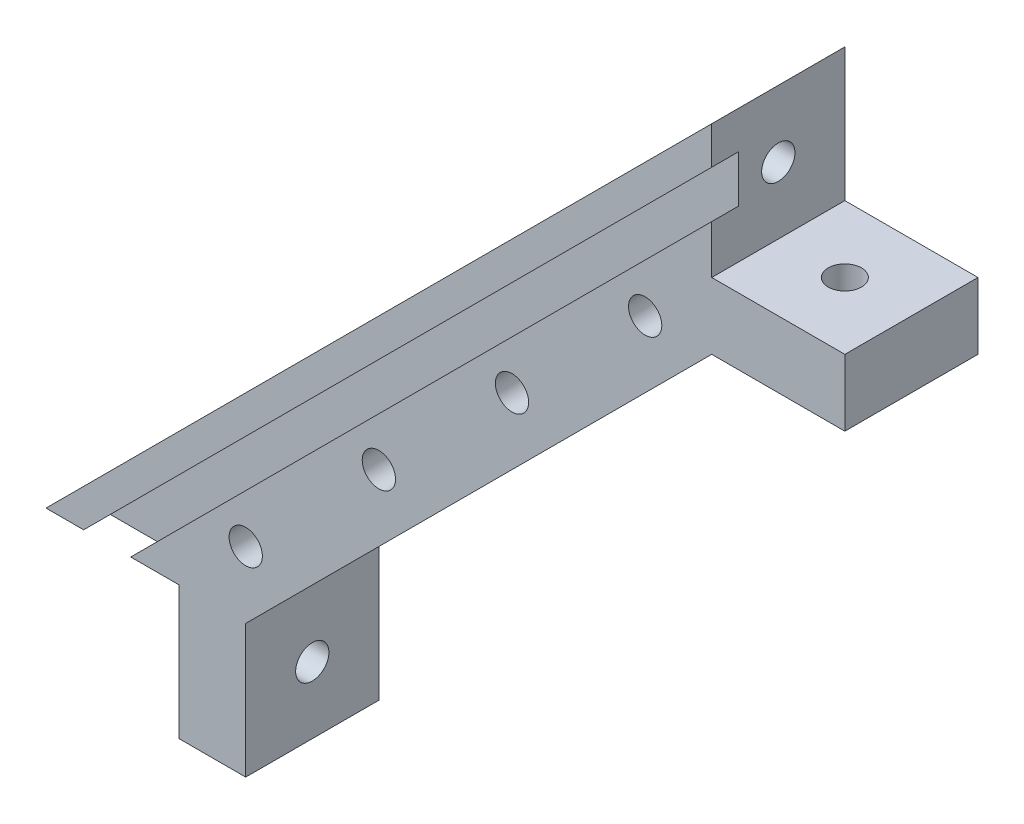
from build123d import *

# Parameters (mm, degrees)
MAIN_DEPTH         = 5
SKETCH2_R          = 1.25
FIXHOLE1_DEPTH     = 51
SKETCH3_R          = 1.25
FIXHOLE2_DEPTH     = 51
WINDOWSLOT1_DEPTH  = 2
SKETCH6_R          = 1.25
CUT_EXTRUDE2_DEPTH = 3
LPATTERN1_COUNT    = 5
LPATTERN1_PITCH    = 10
SKETCH7_R          = 1.25
CUT_EXTRUDE3_DEPTH = 11
LPATTERN2_COUNT    = 4
LPATTERN2_PITCH    = 14.142


with BuildPart() as part:
    # Sketch1 → Main (new body, symmetric)
    with BuildSketch(Plane.XY):
        Polygon((-25, -25), (25, 25), (25, 15), (35, 15), (35, 10), (25, 10), (-10, -25), (-10, -35), (-15, -35), (-15, -25), align=None)
    extrude(amount=MAIN_DEPTH, both=True)

    # Sketch2 → FixHole1 (cut, through all)
    with BuildSketch(Plane(origin=(25, 0, 0), x_dir=(0, 0, -1), z_dir=(1, 0, 0))):
        with Locations((0, -30)):
            Circle(SKETCH2_R)
        with Locations((0, 20)):
            Circle(SKETCH2_R)
    extrude(amount=-FIXHOLE1_DEPTH, mode=Mode.SUBTRACT)

    # Sketch3 → FixHole2 (cut, through all)
    with BuildSketch(Plane(origin=(0, -25, 0), x_dir=(-1, 0, 0), z_dir=(0, -1, 0))):
        with Locations((20, 0)):
            Circle(SKETCH3_R)
        with Locations((-30, 0)):
            Circle(SKETCH3_R)
    extrude(amount=-FIXHOLE2_DEPTH, mode=Mode.SUBTRACT)

    # Sketch4 → WindowSlot1 (cut)
    with BuildSketch(Plane.XY.offset(5)):
        Polygon((25, 22.171572875), (-22.171572875, -25), (-18.636038969, -25), (25, 18.636038969), align=None)
    extrude(amount=-WINDOWSLOT1_DEPTH, mode=Mode.SUBTRACT)

    # Sketch6 → Cut-Extrude2 (cut)
    with BuildSketch(Plane(origin=(7.5, -7.5, 0), x_dir=(0, 0, 1), z_dir=(-0.707106781, 0.707106781, 0))):
        with Locations((0, 20)):
            Circle(SKETCH6_R)
    cut_extrude2 = extrude(amount=CUT_EXTRUDE2_DEPTH, mode=Mode.SUBTRACT)

    # LPattern1: Cut-Extrude2 ×5
    with Locations(*[Vector(-0.707106781, -0.707106781, 0) * (i * LPATTERN1_PITCH) for i in range(1, LPATTERN1_COUNT)]):
        add(cut_extrude2, mode=Mode.SUBTRACT)

    # Sketch7 → Cut-Extrude3 (cut, through all)
    with BuildSketch(Plane(origin=(0, 0, -5), x_dir=(-1, 0, 0), z_dir=(0, 0, -1))):
        with Locations((10, -20)):
            Circle(SKETCH7_R)
    cut_extrude3 = extrude(amount=-CUT_EXTRUDE3_DEPTH, mode=Mode.SUBTRACT)

    # LPattern2: Cut-Extrude3 ×4
    with Locations(*[Vector(0.707106781, 0.707106781, 0) * (i * LPATTERN2_PITCH) for i in range(1, LPATTERN2_COUNT)]):
        add(cut_extrude3, mode=Mode.SUBTRACT)


solid = part.part
